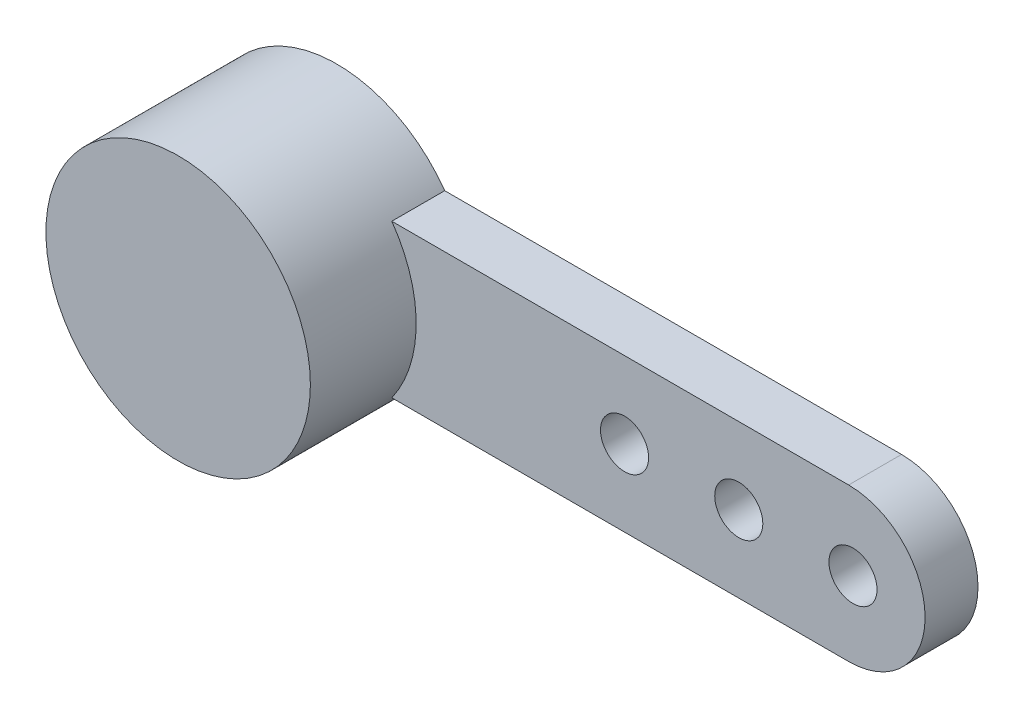
from build123d import *

# Parameters (mm, degrees)
BOSS_EXTRUDE1_DEPTH = 1.1
SKETCH2_R           = 2.75
BOSS_EXTRUDE2_DEPTH = 2.2
CUT_EXTRUDE1_REACH  = 5.3
SKETCH3_R           = 0.5


with BuildPart() as part:
    # Sketch1 → Boss-Extrude1 (new body)
    with BuildSketch(Plane.XY):
        with BuildLine():
            Line((2.243746866, 1.59), (11.743746866, 1.59))
            ThreePointArc((11.743746866, 1.59), (13.333746866, 0), (11.743746866, -1.59))
            Line((11.743746866, -1.59), (2.243746866, -1.59))
            ThreePointArc((2.243746866, -1.59), (-2.75, 0), (2.243746866, 1.59))
        make_face()
    extrude(amount=BOSS_EXTRUDE1_DEPTH)

    # Sketch2 → Boss-Extrude2 (add)
    with BuildSketch(Plane.XY.offset(1.1)):
        Circle(SKETCH2_R)
    extrude(amount=BOSS_EXTRUDE2_DEPTH)

    # Sketch3 → Cut-Extrude1 (cut, up to next)
    with BuildSketch(Plane(origin=(0, 0, 0), x_dir=(-1, 0, 0), z_dir=(0, 0, -1)), mode=Mode.PRIVATE) as cut_extrude1_sk1:
        with Locations((-11.833746866, 0)):
            Circle(SKETCH3_R)
    cut_extrude1_tool1 = extrude(cut_extrude1_sk1.sketch, amount=-CUT_EXTRUDE1_REACH, mode=Mode.PRIVATE) & part.part
    add(cut_extrude1_tool1.solids().sort_by_distance((11.833747, 0, 0))[0], mode=Mode.SUBTRACT)
    # Sketch3 → Cut-Extrude1 (cut, up to next)
    with BuildSketch(Plane(origin=(0, 0, 0), x_dir=(-1, 0, 0), z_dir=(0, 0, -1)), mode=Mode.PRIVATE) as cut_extrude1_sk2:
        with Locations((-9.458746866, 0)):
            Circle(SKETCH3_R)
    cut_extrude1_tool2 = extrude(cut_extrude1_sk2.sketch, amount=-CUT_EXTRUDE1_REACH, mode=Mode.PRIVATE) & part.part
    add(cut_extrude1_tool2.solids().sort_by_distance((9.458747, 0, 0))[0], mode=Mode.SUBTRACT)
    # Sketch3 → Cut-Extrude1 (cut, up to next)
    with BuildSketch(Plane(origin=(0, 0, 0), x_dir=(-1, 0, 0), z_dir=(0, 0, -1)), mode=Mode.PRIVATE) as cut_extrude1_sk3:
        with Locations((-7.083746866, 0)):
            Circle(SKETCH3_R)
    cut_extrude1_tool3 = extrude(cut_extrude1_sk3.sketch, amount=-CUT_EXTRUDE1_REACH, mode=Mode.PRIVATE) & part.part
    add(cut_extrude1_tool3.solids().sort_by_distance((7.083747, 0, 0))[0], mode=Mode.SUBTRACT)


solid = part.part
